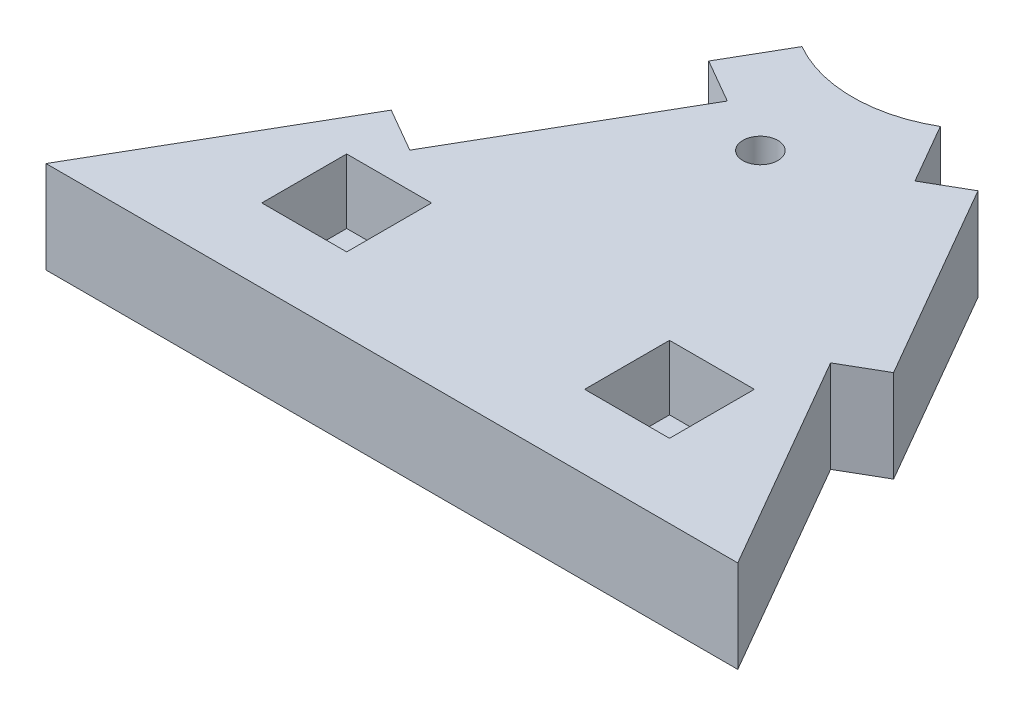
from build123d import *

# Parameters (mm, degrees)
BOSS_EXTRUDE1_DEPTH = 10
SKETCH2_W           = 9.2
SKETCH2_H           = 9.2
CUT_EXTRUDE1_DEPTH  = 7
CUT_EXTRUDE2_DEPTH  = 11
BOSS_EXTRUDE2_DEPTH = 10
SKETCH5_R           = 1.9
CUT_EXTRUDE3_DEPTH  = 11


with BuildPart() as part:
    # Sketch1 → Boss-Extrude1 (new body)
    with BuildSketch(Plane(origin=(0, 0, 0), x_dir=(1, 0, 0), z_dir=(0, 1, 0))):
        Polygon((0, 0), (75, 0), (37.5, 64.951905284), align=None)
    extrude(amount=BOSS_EXTRUDE1_DEPTH)

    # Sketch2 → Cut-Extrude1 (cut)
    with BuildSketch(Plane(origin=(0, 10, 0), x_dir=(1, 0, 0), z_dir=(0, 1, 0))):
        with Locations((55, 12.6)):
            Rectangle(SKETCH2_W, SKETCH2_H)
        with Locations((20, 12.6)):
            Rectangle(SKETCH2_W, SKETCH2_H)
    extrude(amount=-CUT_EXTRUDE1_DEPTH, mode=Mode.SUBTRACT)

    # Sketch3 → Cut-Extrude2 (cut, through all)
    with BuildSketch(Plane(origin=(0, 10, 0), x_dir=(1, 0, 0), z_dir=(0, 1, 0))):
        Polygon((18.75, 32.475952642), (26.3, 45.552936239), (31.063139721, 42.802936239), (18.463139721, 20.979096064), (13.7, 23.729096064), align=None)
    extrude(amount=-CUT_EXTRUDE2_DEPTH, mode=Mode.SUBTRACT)

    # Sketch4 → Boss-Extrude2 (add)
    with BuildSketch(Plane(origin=(0, 10, 0), x_dir=(1, 0, 0), z_dir=(0, 1, 0))):
        Polygon((56.25, 32.475952642), (48.75, 45.466333699), (53.080127019, 47.966333699), (65.580127019, 26.315698604), (61.25, 23.815698604), align=None)
    extrude(amount=-BOSS_EXTRUDE2_DEPTH)

    # Sketch5 → Cut-Extrude3 (cut, through all)
    with BuildSketch(Plane(origin=(0, 10, 0), x_dir=(1, 0, 0), z_dir=(0, 1, 0))):
        with Locations((37.5, 39.951905284)):
            Circle(SKETCH5_R)
        with BuildLine():
            Line((30, 51.961524227), (37.5, 64.951905284))
            Line((37.5, 64.951905284), (45, 51.961524227))
            ThreePointArc((45, 51.961524227), (37.5, 49.951905284), (30, 51.961524227))
        make_face()
    extrude(amount=-CUT_EXTRUDE3_DEPTH, mode=Mode.SUBTRACT)


solid = part.part
